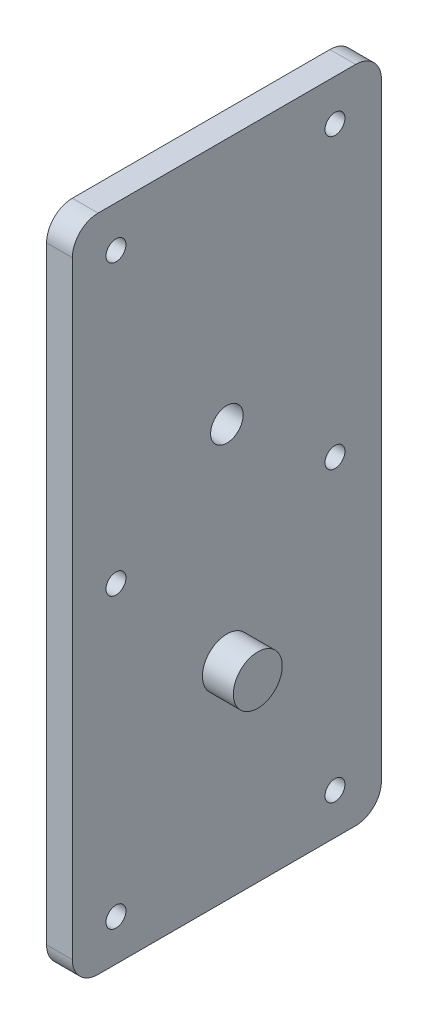
from build123d import *

# Parameters (mm, degrees)
RIGHT_PLATE_DEPTH         = 6.35
SKETCH5_R                 = 6.0325
SPOOL_POST_DEPTH          = 7.62
F_8_CLEARANCE_HOLE1_D     = 4.9149
F_8_CLEARANCE_HOLE1_DEPTH = 6.35
O_0_316_DIAMETER_HOLE3_D  = 8.0264


with BuildPart() as part:
    # Sketch1 → Right plate (new body)
    with BuildSketch(Plane(origin=(0, 0, 0), x_dir=(0, 0, -1), z_dir=(1, 0, 0))):
        with BuildLine():
            Line((-31.75, -50.8), (31.75, -50.8))
            ThreePointArc((31.75, -50.8), (36.240128061, -48.940128061), (38.1, -44.45))
            Line((38.1, -44.45), (38.1, 105.41))
            ThreePointArc((38.1, 105.41), (36.240128061, 109.900128061), (31.75, 111.76))
            Line((31.75, 111.76), (-31.75, 111.76))
            ThreePointArc((-31.75, 111.76), (-36.240128061, 109.900128061), (-38.1, 105.41))
            Line((-38.1, 105.41), (-38.1, -44.45))
            ThreePointArc((-38.1, -44.45), (-36.240128061, -48.940128061), (-31.75, -50.8))
        make_face()
    extrude(amount=RIGHT_PLATE_DEPTH)

    # Sketch5 → Spool post (add)
    with BuildSketch(Plane(origin=(6.35, 0, 0), x_dir=(0, 0, -1), z_dir=(1, 0, 0))):
        Circle(SKETCH5_R)
    extrude(amount=SPOOL_POST_DEPTH)

    # #8 Clearance Hole1
    with Locations(Plane.ZY):
        with Locations((-26.646533, 101.600261), (27.342012, 101.600261), (27.342012, 30.480261), (-26.646533, 30.480261), (-26.646533, -40.639739), (27.342012, -40.639739)):
            Hole(F_8_CLEARANCE_HOLE1_D / 2, depth=F_8_CLEARANCE_HOLE1_DEPTH)

    # O (0.316) Diameter Hole3 (through all)
    with Locations(Plane(origin=(6.35, 0, 0), x_dir=(0, 0, -1), z_dir=(1, 0, 0))):
        with Locations((-675.189894138, -31.321376827), (0, 50.8)):
            Hole(O_0_316_DIAMETER_HOLE3_D / 2)


solid = part.part
